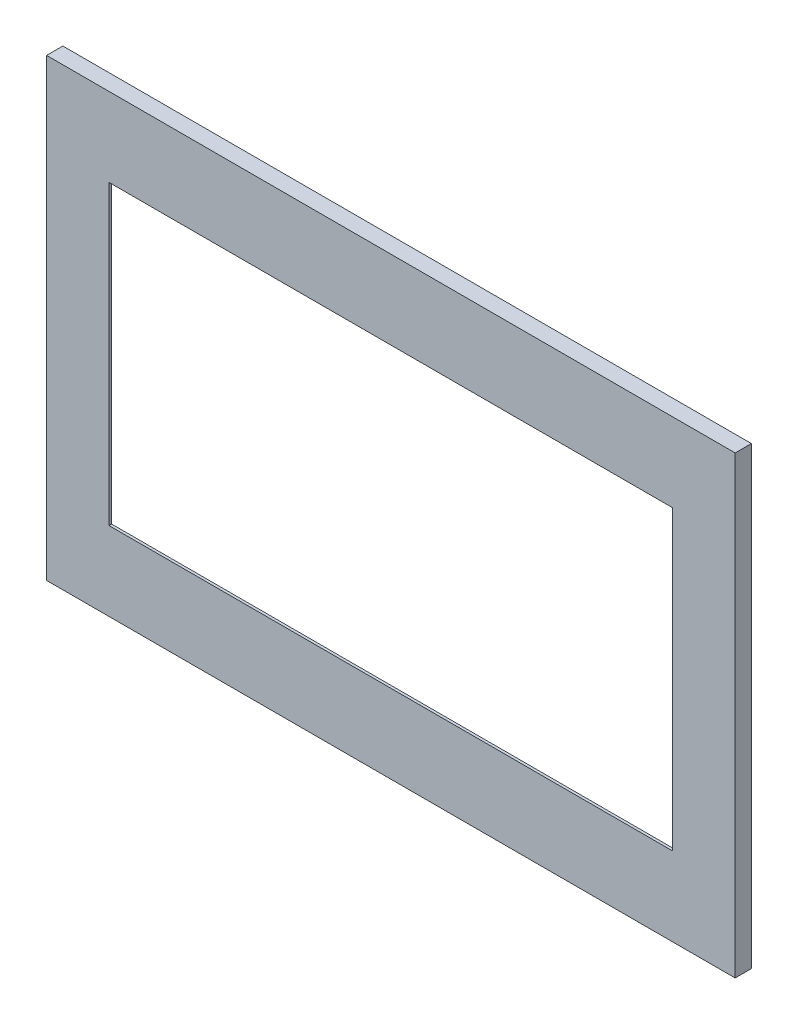
from build123d import *

# Parameters (mm, degrees)
SKETCH1_W               = 673.1
SKETCH1_H               = 444.5
BOSS_EXTRUDE1_DEPTH     = 7.9375
SKETCH2_W               = 601.6625
SKETCH2_H               = 341.3125
CUT_EXTRUDE1_DEPTH      = 1
CUT_EXTRUDE1_DEPTH_BACK = 16.875
SKETCH8_W               = 601.6625
SKETCH8_H               = 341.3125
SKETCH8_W_2             = 550.8625
SKETCH8_H_2             = 290.5125
BOSS_EXTRUDE3_DEPTH     = 2.54


with BuildPart() as part:
    # Sketch1 → Boss-Extrude1 (new body, symmetric)
    with BuildSketch(Plane.XY):
        Rectangle(SKETCH1_W, SKETCH1_H)
    extrude(amount=BOSS_EXTRUDE1_DEPTH, both=True)

    # Sketch2 → Cut-Extrude1 (cut, two sides)
    with BuildSketch(Plane.XY.offset(7.9375)) as cut_extrude1_sk:
        Rectangle(SKETCH2_W, SKETCH2_H)
    extrude(amount=CUT_EXTRUDE1_DEPTH, mode=Mode.SUBTRACT)
    extrude(cut_extrude1_sk.sketch, amount=-CUT_EXTRUDE1_DEPTH_BACK, mode=Mode.SUBTRACT)

    # Sketch8 → Boss-Extrude3 (add)
    with BuildSketch(Plane.XY.offset(7.9375)):
        Rectangle(SKETCH8_W, SKETCH8_H)
        Rectangle(SKETCH8_W_2, SKETCH8_H_2, mode=Mode.SUBTRACT)
    extrude(amount=-BOSS_EXTRUDE3_DEPTH)


solid = part.part
